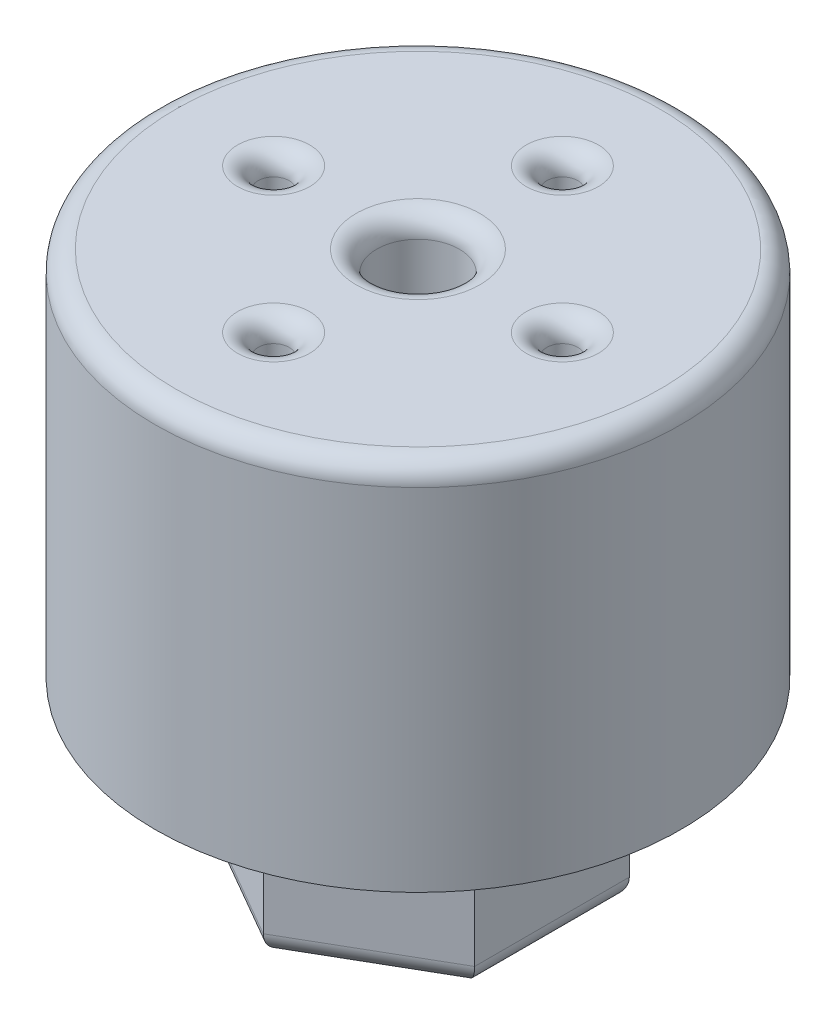
from build123d import *

# Parameters (mm, degrees)
CROQUIS1_R              = 12.75
CROQUIS1_R_2            = 0.75
SALIENTE_EXTRUIR1_DEPTH = 18
SALIENTE_EXTRUIR3_DEPTH = 8
CROQUIS4_R              = 12.75
SALIENTE_EXTRUIR4_DEPTH = 4
CROQUIS5_R              = 2
CORTAR_EXTRUIR1_DEPTH   = 27
REDONDEO1_R             = 1
REDONDEO2_R             = 1


with BuildPart() as part:
    # Croquis1 → Saliente-Extruir1 (new body)
    with BuildSketch(Plane(origin=(0, 0, 0), x_dir=(1, 0, 0), z_dir=(0, 1, 0))):
        Circle(CROQUIS1_R)
        with Locations((0, 7)):
            Circle(CROQUIS1_R_2, mode=Mode.SUBTRACT)
        with Locations((7, 0)):
            Circle(CROQUIS1_R_2, mode=Mode.SUBTRACT)
        with Locations((0, -7)):
            Circle(CROQUIS1_R_2, mode=Mode.SUBTRACT)
        with Locations((-7, 0)):
            Circle(CROQUIS1_R_2, mode=Mode.SUBTRACT)
    extrude(amount=SALIENTE_EXTRUIR1_DEPTH)

    # Croquis3 → Saliente-Extruir3 (add)
    with BuildSketch(Plane.XZ):
        Polygon((0, 7.5), (-6.495190528, 3.75), (-6.495190528, -3.75), (0, -7.5), (6.495190528, -3.75), (6.495190528, 3.75), align=None)
    extrude(amount=SALIENTE_EXTRUIR3_DEPTH)

    # Croquis4 → Saliente-Extruir4 (add)
    with BuildSketch(Plane.XZ):
        Circle(CROQUIS4_R)
    extrude(amount=-SALIENTE_EXTRUIR4_DEPTH)

    # Croquis5 → Cortar-Extruir1 (cut, through all)
    with BuildSketch(Plane.XZ.offset(8)):
        Circle(CROQUIS5_R)
    extrude(amount=-CORTAR_EXTRUIR1_DEPTH, mode=Mode.SUBTRACT)

    # Redondeo1
    redondeo1_edges = [part.edges().sort_by_distance(p)[0] for p in [
        (3.247595264, -8, 5.625),
        (-3.247595264, -8, 5.625),
        (-6.495190528, -8, 0),
        (-3.247595264, -8, -5.625),
        (3.247595264, -8, -5.625),
        (6.495190528, -8, 0),
        (-2, -8, 0),
    ]]
    fillet(redondeo1_edges, radius=REDONDEO1_R)

    # Redondeo2
    redondeo2_edges = [part.edges().sort_by_distance(p)[0] for p in [
        (-0.75, 18, 7),
        (-7.75, 18, 0),
        (-12.75, 18, 0),
        (-0.75, 18, -7),
        (-2, 18, 0),
        (6.25, 18, 0),
    ]]
    fillet(redondeo2_edges, radius=REDONDEO2_R)


solid = part.part
